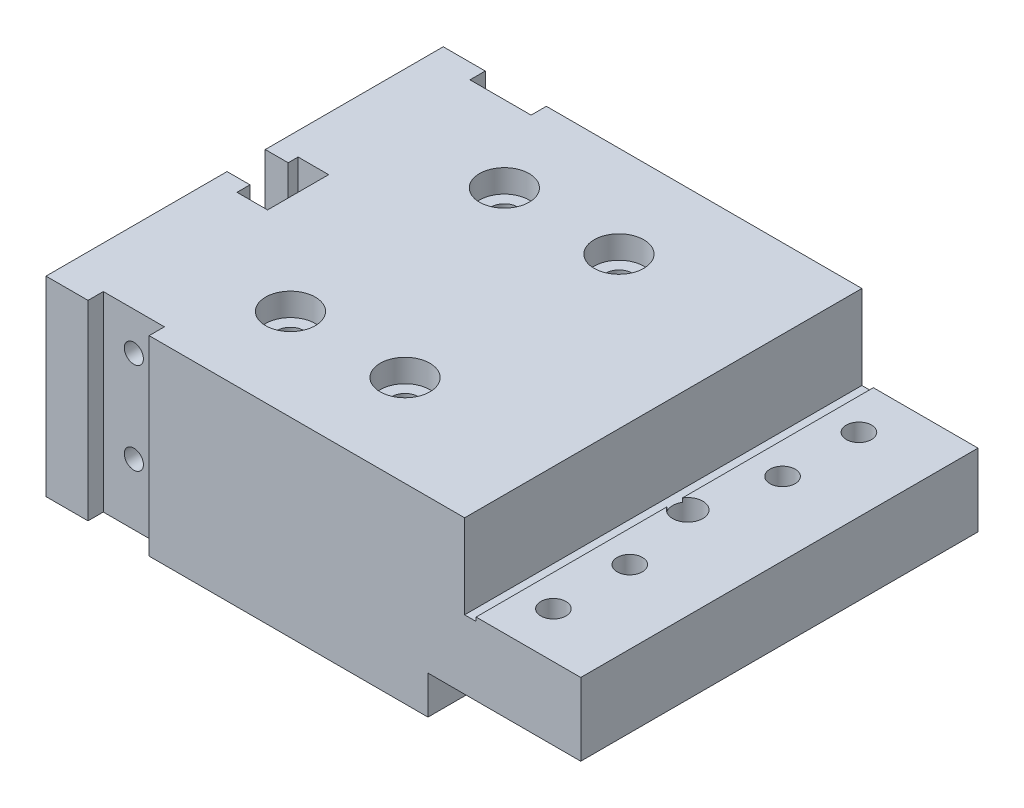
from build123d import *

# Parameters (mm, degrees)
BOSS_EXTRUDE1_DEPTH   = 52
SKETCH2_R             = 1.7
SKETCH2_W             = 8
SKETCH2_H             = 2
CUT_EXTRUDE1_DEPTH    = 52
SKETCH3_R             = 3.25
CUT_EXTRUDE2_DEPTH    = 3
SKETCH4_R             = 1.9780711
CUT_EXTRUDE3_DEPTH    = 15.5
M4_TAPPED_HOLE1_D     = 3.3
M4_TAPPED_HOLE1_DEPTH = 10.1
M4_TAPPED_HOLE1_TIP   = 0.991420021
SKETCH7_W             = 40
SKETCH7_H             = 3
CUT_EXTRUDE4_DEPTH    = 51
M3_TAPPED_HOLE1_D     = 2.5
M3_TAPPED_HOLE1_DEPTH = 7.5
M3_TAPPED_HOLE1_TIP   = 0.751075774
M3_TAPPED_HOLE2_D     = 2.5
M3_TAPPED_HOLE2_DEPTH = 7.5
M3_TAPPED_HOLE2_TIP   = 0.751075774


with BuildPart() as part:
    # Sketch1 → Boss-Extrude1 (new body)
    with BuildSketch(Plane.XY):
        Polygon((-25.815712776, -13.506468073), (28.984287224, -13.506468073), (28.984287224, -24.506468073), (30.484287224, -24.506468073), (30.484287224, -24.006468073), (44.184287224, -24.006468073), (44.184287224, -33.506468073), (24.184287224, -33.506468073), (24.184287224, -38.506468073), (-25.815712776, -38.506468073), align=None)
    extrude(amount=BOSS_EXTRUDE1_DEPTH)

    # Sketch2 → Cut-Extrude1 (cut)
    with BuildSketch(Plane(origin=(0, -13.506468073, 0), x_dir=(1, 0, 0), z_dir=(0, 1, 0))):
        with Locations((-5.815712776, -12)):
            Circle(SKETCH2_R)
        with Locations((9.184287224, -12)):
            Circle(SKETCH2_R)
        with Locations((-5.815712776, -40)):
            Circle(SKETCH2_R)
        with Locations((9.184287224, -40)):
            Circle(SKETCH2_R)
        with Locations((-16.315712776, -51)):
            Rectangle(SKETCH2_W, SKETCH2_H)
        with Locations((-16.315712776, -1)):
            Rectangle(SKETCH2_W, SKETCH2_H)
        Polygon((-22.815712776, -23.3), (-25.815712776, -23.3), (-25.815712776, -28.3), (-22.815712776, -28.3), (-22.815712776, -30), (-18.815712776, -30), (-18.815712776, -22), (-22.815712776, -22), align=None)
    extrude(amount=-CUT_EXTRUDE1_DEPTH, mode=Mode.SUBTRACT)

    # Sketch3 → Cut-Extrude2 (cut)
    with BuildSketch(Plane(origin=(0, -13.506468073, 0), x_dir=(1, 0, 0), z_dir=(0, 1, 0))):
        with Locations((-5.815712776, -12)):
            Circle(SKETCH3_R)
        with Locations((9.184287224, -12)):
            Circle(SKETCH3_R)
        with Locations((9.184287224, -40)):
            Circle(SKETCH3_R)
        with Locations((-5.815712776, -40)):
            Circle(SKETCH3_R)
    extrude(amount=-CUT_EXTRUDE2_DEPTH, mode=Mode.SUBTRACT)

    # Sketch4 → Cut-Extrude3 (cut, through all)
    with BuildSketch(Plane(origin=(0, -24.006468073, 0), x_dir=(1, 0, 0), z_dir=(0, 1, 0))):
        with Locations((32.184287224, -26)):
            Circle(SKETCH4_R)
    extrude(amount=-CUT_EXTRUDE3_DEPTH, mode=Mode.SUBTRACT)

    # M4 Tapped Hole1
    with Locations(Plane(origin=(0, -24.006468073, 0), x_dir=(1, 0, 0), z_dir=(0, 1, 0))):
        with Locations((34.600682557, -6), (34.600682557, -16), (34.600682557, -36), (34.600682557, -46)):
            Hole(M4_TAPPED_HOLE1_D / 2, depth=M4_TAPPED_HOLE1_DEPTH)
            with Locations((0, 0, -(M4_TAPPED_HOLE1_DEPTH + M4_TAPPED_HOLE1_TIP / 2))):  # 118° drill point
                Cone(0, M4_TAPPED_HOLE1_D / 2, M4_TAPPED_HOLE1_TIP, mode=Mode.SUBTRACT)

    # Sketch7 → Cut-Extrude4 (cut, through all)
    with BuildSketch(Plane(origin=(24.184287224, 0, 0), x_dir=(0, 0, -1), z_dir=(1, 0, 0))):
        with Locations((-26, -37.006468073)):
            Rectangle(SKETCH7_W, SKETCH7_H)
    extrude(amount=-CUT_EXTRUDE4_DEPTH, mode=Mode.SUBTRACT)

    # M3 Tapped Hole1
    with Locations(Plane.XY.offset(50)):
        with Locations((-16.315712776, -18.506468073), (-16.315712776, -30.506468073)):
            Hole(M3_TAPPED_HOLE1_D / 2, depth=M3_TAPPED_HOLE1_DEPTH)
            with Locations((0, 0, -(M3_TAPPED_HOLE1_DEPTH + M3_TAPPED_HOLE1_TIP / 2))):  # 118° drill point
                Cone(0, M3_TAPPED_HOLE1_D / 2, M3_TAPPED_HOLE1_TIP, mode=Mode.SUBTRACT)

    # M3 Tapped Hole2
    with Locations(Plane(origin=(0, 0, 2), x_dir=(-1, 0, 0), z_dir=(0, 0, -1))):
        with Locations((16.315712776, -18.506468073), (16.315712776, -30.506468073)):
            Hole(M3_TAPPED_HOLE2_D / 2, depth=M3_TAPPED_HOLE2_DEPTH)
            with Locations((0, 0, -(M3_TAPPED_HOLE2_DEPTH + M3_TAPPED_HOLE2_TIP / 2))):  # 118° drill point
                Cone(0, M3_TAPPED_HOLE2_D / 2, M3_TAPPED_HOLE2_TIP, mode=Mode.SUBTRACT)


solid = part.part
